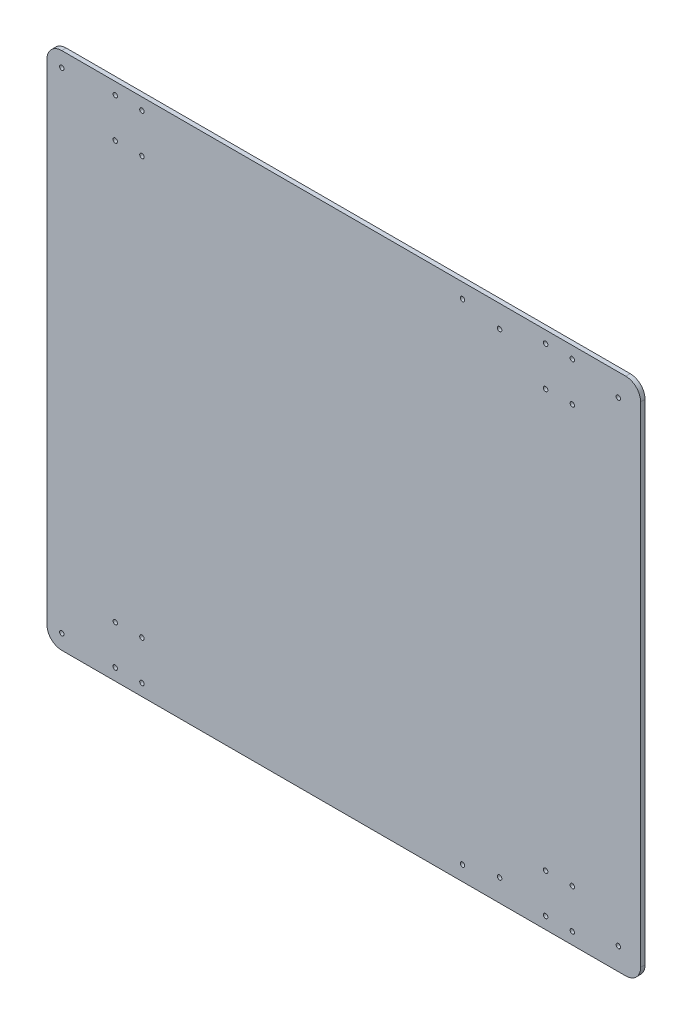
from build123d import *

# Parameters (mm, degrees)
ESQUISSE1_R             = 1.5
BOSS_EXTRU_2_DEPTH      = 3
ESQUISSE2_R             = 1.5
ENL_V_MAT_EXTRU_1_DEPTH = 10


with BuildPart() as part:
    # Esquisse1 → Boss.-Extru.2 (new body)
    with BuildSketch(Plane.XY):
        with BuildLine():
            Line((10, 0), (390, 0))
            ThreePointArc((390, 0), (397.071067812, 2.928932188), (400, 10))
            Line((400, 10), (400, 340))
            ThreePointArc((400, 340), (397.071067812, 347.071067812), (390, 350))
            Line((390, 350), (10, 350))
            ThreePointArc((10, 350), (2.928932188, 347.071067812), (0, 340))
            Line((0, 340), (0, 10))
            ThreePointArc((0, 10), (2.928932188, 2.928932188), (10, 0))
        make_face()
        with Locations((385, 15)):
            Circle(ESQUISSE1_R, mode=Mode.SUBTRACT)
        with Locations((305, 15)):
            Circle(ESQUISSE1_R, mode=Mode.SUBTRACT)
        with Locations((305, 335)):
            Circle(ESQUISSE1_R, mode=Mode.SUBTRACT)
        with Locations((385, 335)):
            Circle(ESQUISSE1_R, mode=Mode.SUBTRACT)
        with Locations((354, 8)):
            Circle(ESQUISSE1_R, mode=Mode.SUBTRACT)
        with Locations((336, 8)):
            Circle(ESQUISSE1_R, mode=Mode.SUBTRACT)
        with Locations((336, 34.48)):
            Circle(ESQUISSE1_R, mode=Mode.SUBTRACT)
        with Locations((354, 34.48)):
            Circle(ESQUISSE1_R, mode=Mode.SUBTRACT)
        with Locations((336, 342)):
            Circle(ESQUISSE1_R, mode=Mode.SUBTRACT)
        with Locations((336, 315.52)):
            Circle(ESQUISSE1_R, mode=Mode.SUBTRACT)
        with Locations((354, 315.52)):
            Circle(ESQUISSE1_R, mode=Mode.SUBTRACT)
        with Locations((354, 342)):
            Circle(ESQUISSE1_R, mode=Mode.SUBTRACT)
        with Locations((64, 34.48)):
            Circle(ESQUISSE1_R, mode=Mode.SUBTRACT)
        with Locations((46, 34.48)):
            Circle(ESQUISSE1_R, mode=Mode.SUBTRACT)
        with Locations((46, 8)):
            Circle(ESQUISSE1_R, mode=Mode.SUBTRACT)
        with Locations((64, 8)):
            Circle(ESQUISSE1_R, mode=Mode.SUBTRACT)
        with Locations((46, 315.52)):
            Circle(ESQUISSE1_R, mode=Mode.SUBTRACT)
        with Locations((46, 342)):
            Circle(ESQUISSE1_R, mode=Mode.SUBTRACT)
        with Locations((64, 342)):
            Circle(ESQUISSE1_R, mode=Mode.SUBTRACT)
        with Locations((64, 315.52)):
            Circle(ESQUISSE1_R, mode=Mode.SUBTRACT)
    extrude(amount=BOSS_EXTRU_2_DEPTH)

    # Esquisse2 → Enlèv. mat.-Extru.1 (cut)
    with BuildSketch(Plane(origin=(0, 0, 0), x_dir=(-1, 0, 0), z_dir=(0, 0, -1))):
        with Locations((-10, 10)):
            Circle(ESQUISSE2_R)
        with Locations((-10, 340)):
            Circle(ESQUISSE2_R)
        with Locations((-280, 340)):
            Circle(ESQUISSE2_R)
        with Locations((-280, 10)):
            Circle(ESQUISSE2_R)
    extrude(amount=-ENL_V_MAT_EXTRU_1_DEPTH, mode=Mode.SUBTRACT)


solid = part.part
